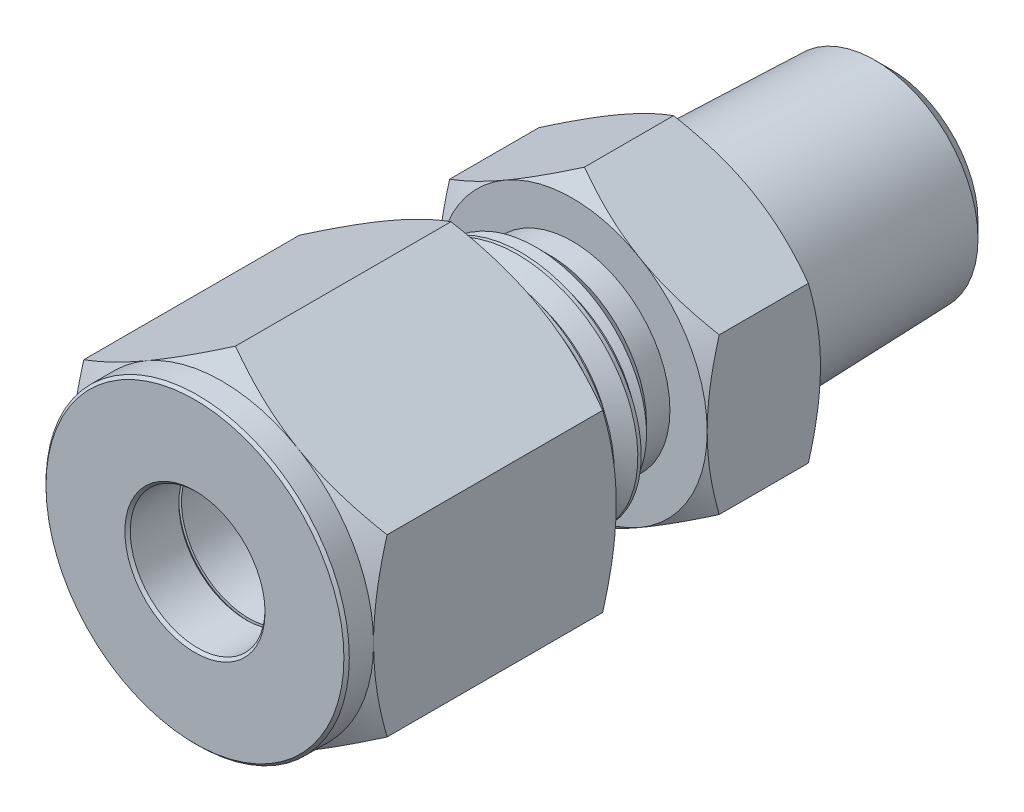
from build123d import *

# Parameters (mm, degrees)
BOSS_EXTRUDE1_DEPTH    = 12.7
CHAMFER1_SIZE          = 0.127
SKETCH4_W              = 15.748
SKETCH4_H              = 5.55625
CUT_SWEEP1_PITCH       = 1.27
CUT_SWEEP1_HEIGHT      = 17.018
CUT_SWEEP1_RADIUS      = 5.55625
CUT_SWEEP1_START_ANGLE = 90
BOSS_EXTRUDE2_DEPTH    = 5.334


with BuildPart() as part:
    # Sketch2 → Boss-Extrude1 (new body)
    with BuildSketch(Plane.XY):
        Polygon((0, 8.248892), (-7.14375, 4.124446), (-7.14375, -4.124446), (0, -8.248892), (7.14375, -4.124446), (7.14375, 4.124446), align=None)
    extrude(amount=-BOSS_EXTRUDE1_DEPTH)

    # Sketch3 → Cut-Revolve1 (revolve, cut)
    with BuildSketch(Plane(origin=(0, 0, 0), x_dir=(0, 0, -1), z_dir=(1, 0, 0)), mode=Mode.PRIVATE) as cut_revolve1_sk:
        Polygon((0, 8.248892), (0, 7.14375), (1.27, 7.14375), (1.908054, 8.248892), (12.061946, 8.248892), (12.7, 7.14375), (12.7, 8.248892), (12.7, 9.354034), (0, 9.354034), align=None)
        Polygon((0, 3.175), (0, 0), (12.7, 0), (12.7, 5.55625), (5.08, 5.55625), (5.08, 4.92125), (2.54, 4.92125), (2.54, 4.28625), (2.54, 3.175), align=None)
    revolve(cut_revolve1_sk.sketch.rotate(Axis((0, 0, 0), (0, 0, -1)), 90), axis=Axis((0, 0, 0), (0, 0, -1)), mode=Mode.SUBTRACT)

    # Chamfer1
    chamfer1_edges = [part.edges().sort_by_distance(p)[0] for p in [
        (-7.14375, 0, 0),
        (-3.175, 0, -2.54),
        (-3.175, 0, 0),
    ]]
    chamfer(chamfer1_edges, length=CHAMFER1_SIZE)


with BuildPart() as body_2:
    # Sketch4 → Revolve1 (revolve)
    with BuildSketch(Plane(origin=(0, 0, 0), x_dir=(0, 0, -1), z_dir=(1, 0, 0)), mode=Mode.PRIVATE) as revolve1_sk:
        with Locations((15.24, 2.778125)):
            Rectangle(SKETCH4_W, SKETCH4_H)
    revolve(revolve1_sk.sketch.rotate(Axis((0, 0, -23.114), (0, 0, 1)), 90), axis=Axis((0, 0, -23.114), (0, 0, 1)))

    # Cut-Sweep1: sweep along a helix
    with BuildLine() as cut_sweep1_path:
        add(Helix(CUT_SWEEP1_PITCH, CUT_SWEEP1_HEIGHT, CUT_SWEEP1_RADIUS, center=(0, 0, -7.366), direction=(0, 0, -1), mode=Mode.PRIVATE).rotate(Axis((0, 0, -7.366), (0, 0, -1)), CUT_SWEEP1_START_ANGLE))
    # Sketch6 → Cut-Sweep1 (sweep, cut)
    with BuildSketch(Plane(origin=(0, 0, 0), x_dir=(0, 0, -1), z_dir=(1, 0, 0))):
        Polygon((6.731, 4.731361), (6.215063, 5.624991), (7.405688, 5.624991), (6.88975, 4.731361), align=None)
    sweep(path=cut_sweep1_path.line, is_frenet=True, mode=Mode.SUBTRACT)

    # Sketch7 → Boss-Extrude2 (add)
    with BuildSketch(Plane(origin=(0, 0, -23.114), x_dir=(-1, 0, 0), z_dir=(0, 0, -1))):
        Polygon((0, 7.332348), (-6.35, 3.666174), (-6.35, -3.666174), (0, -7.332348), (6.35, -3.666174), (6.35, 3.666174), align=None)
    extrude(amount=-BOSS_EXTRUDE2_DEPTH)

    # Sketch8 → Cut-Revolve2 (revolve, cut)
    with BuildSketch(Plane(origin=(0, 0, 0), x_dir=(0, 0, -1), z_dir=(1, 0, 0)), mode=Mode.PRIVATE) as cut_revolve2_sk:
        Polygon((7.366, 5.693732), (7.366, 4.593879), (8.465852, 5.693732), align=None)
        Polygon((17.78, 5.693732), (15.580295, 5.693732), (16.680148, 4.593879), (17.78, 4.593879), align=None)
        Polygon((17.78, 6.35), (18.347159, 7.332348), (22.546841, 7.332348), (23.114, 6.35), (23.114, 7.332348), (23.114, 8.314697), (17.78, 8.314697), (17.78, 7.332348), align=None)
        Polygon((15.24, 2.3749), (23.114, 2.3749), (23.114, 0), (7.366, 0), (7.366, 4.044818), (11.249837, 3.175), (15.24, 3.175), align=None)
    revolve(cut_revolve2_sk.sketch.rotate(Axis((0, 0, 0), (0, 0, -1)), 90), axis=Axis((0, 0, 0), (0, 0, -1)), mode=Mode.SUBTRACT)


with BuildPart() as body_3:
    # Sketch9 → Revolve2 (revolve)
    with BuildSketch(Plane(origin=(0, 0, 0), x_dir=(0, 0, -1), z_dir=(1, 0, 0)), mode=Mode.PRIVATE) as revolve2_sk:
        Polygon((4.445, 4.699), (4.445, 3.8608), (5.1308, 3.175), (9.3218, 3.175), (9.3218, 3.6068), align=None)
    revolve(revolve2_sk.sketch.rotate(Axis((0, 0, 0), (0, 0, -1)), 90), axis=Axis((0, 0, 0), (0, 0, -1)))


with BuildPart() as body_4:
    # Sketch10 → Revolve3 (revolve)
    with BuildSketch(Plane(origin=(0, 0, 0), x_dir=(0, 0, -1), z_dir=(1, 0, 0)), mode=Mode.PRIVATE) as revolve3_sk:
        Polygon((2.54, 4.6609), (3.556, 4.6609), (3.556, 3.8608), (4.445, 3.8608), (5.1308, 3.175), (2.54, 3.175), align=None)
    revolve(revolve3_sk.sketch.rotate(Axis((0, 0, 0), (0, 0, -1)), 90), axis=Axis((0, 0, 0), (0, 0, -1)))


with BuildPart() as body_5:
    # Sketch11 → Revolve4 (revolve)
    with BuildSketch(Plane(origin=(0, 0, 0), x_dir=(0, 0, -1), z_dir=(1, 0, 0)), mode=Mode.PRIVATE) as revolve4_sk:
        Polygon((22.79904, 0), (32.766, 0), (32.766, 4.833178), (22.79904, 5.1435), align=None)
    revolve(revolve4_sk.sketch.rotate(Axis((0, 0, -22.79904), (0, 0, -1)), 90), axis=Axis((0, 0, -22.79904), (0, 0, -1)))


with BuildPart() as body_2_1:
    add(body_2.part)

    # Combine1: union body 5
    add(body_5.part)

    # Sketch14 → Cut-Revolve4 (revolve, cut)
    with BuildSketch(Plane(origin=(0, 0, 0), x_dir=(0, 0, -1), z_dir=(1, 0, 0)), mode=Mode.PRIVATE) as cut_revolve4_sk:
        Polygon((32.766, 4.120311), (31.951295, 4.935016), (32.766, 4.935016), align=None)
        Polygon((32.766, 3.4163), (22.79904, 3.4163), (20.74632, 0), (32.766, 0), align=None)
    revolve(cut_revolve4_sk.sketch.rotate(Axis((0, 0, 0), (0, 0, -1)), 90), axis=Axis((0, 0, 0), (0, 0, -1)), mode=Mode.SUBTRACT)


solid = Compound([part.part, body_3.part, body_4.part, body_2_1.part])
